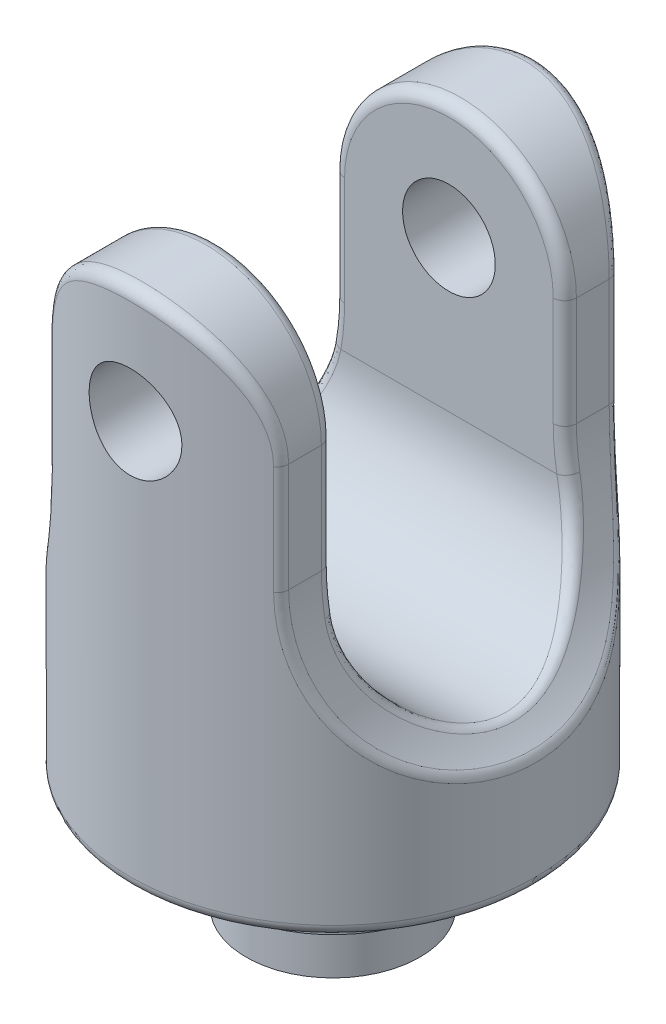
from build123d import *

# Parameters (mm, degrees)
SKETCH_1_R               = 17.5
EXTRUDE_1_DEPTH          = 45
CUT_EXTRUDE_1_DEPTH      = 18.5
CUT_EXTRUDE_1_DEPTH_BACK = 18.5
CUT_EXTRUDE_3_DEPTH      = 18.5000001
CUT_EXTRUDE_3_DEPTH_BACK = 18.5000001
SKETCH_4_R               = 4
CUT_EXTRUDE_4_DEPTH      = 18.5000001
CUT_EXTRUDE_4_DEPTH_BACK = 18.5000001
SKETCH_5_R               = 10
EXTRUDE_2_DEPTH          = 5
SKETCH_6_R               = 7.5
EXTRUDE_3_DEPTH          = 5
FILLET_1_R               = 1


with BuildPart() as part:
    # 草图1 → 凸台-拉伸1 (new body)
    with BuildSketch(Plane(origin=(0, 0, 0), x_dir=(1, 0, 0), z_dir=(0, 1, 0))):
        Circle(SKETCH_1_R)
    extrude(amount=EXTRUDE_1_DEPTH)

    # 草图2 → 切除-拉伸1 (cut, two sides)
    with BuildSketch(Plane.XY) as cut_extrude_1_sk:
        with BuildLine():
            Line((102.584155078, -58.121843354), (17.5, 10))
            ThreePointArc((17.5, 10), (11.972243623, 16.952240958), (10, 25.612494996))
            Line((10, 25.612494996), (10, 35))
            ThreePointArc((10, 35), (0, 45), (-10, 35))
            Line((-10, 35), (-10, 25.612494996))
            ThreePointArc((-10, 25.612494996), (-11.972243623, 16.952240958), (-17.5, 10))
            Line((-17.5, 10), (-102.584155078, -58.121843354))
            Line((-102.584155078, -58.121843354), (-102.584155078, 159.868055378))
            Line((-102.584155078, 159.868055378), (102.584155078, 159.868055378))
            Line((102.584155078, 159.868055378), (102.584155078, -58.121843354))
        make_face()
    extrude(amount=CUT_EXTRUDE_1_DEPTH, mode=Mode.SUBTRACT)
    extrude(cut_extrude_1_sk.sketch, amount=-CUT_EXTRUDE_1_DEPTH_BACK, mode=Mode.SUBTRACT)

    # 草图3 → 切除-拉伸3 (cut, two sides)
    with BuildSketch(Plane(origin=(0, 0, 0), x_dir=(0, 0, -1), z_dir=(1, 0, 0))) as cut_extrude_3_sk:
        with BuildLine():
            Line((-10, 45), (-10, 22))
            ThreePointArc((-10, 22), (0, 12), (10, 22))
            Line((10, 22), (10, 45))
            Line((10, 45), (-10, 45))
        make_face()
    extrude(amount=CUT_EXTRUDE_3_DEPTH, mode=Mode.SUBTRACT)
    extrude(cut_extrude_3_sk.sketch, amount=-CUT_EXTRUDE_3_DEPTH_BACK, mode=Mode.SUBTRACT)

    # 草图4 → 切除-拉伸4 (cut, two sides)
    with BuildSketch(Plane.XY) as cut_extrude_4_sk:
        with Locations((0, 35)):
            Circle(SKETCH_4_R)
    extrude(amount=CUT_EXTRUDE_4_DEPTH, mode=Mode.SUBTRACT)
    extrude(cut_extrude_4_sk.sketch, amount=-CUT_EXTRUDE_4_DEPTH_BACK, mode=Mode.SUBTRACT)

    # 草图5 → 凸台-拉伸2 (add)
    with BuildSketch(Plane.XZ):
        Circle(SKETCH_5_R)
    extrude(amount=EXTRUDE_2_DEPTH)

    # 草图6 → 凸台-拉伸3 (add)
    with BuildSketch(Plane.XZ.offset(5)):
        Circle(SKETCH_6_R)
    extrude(amount=EXTRUDE_3_DEPTH)

    # 圆角1
    fillet_1_edges = [part.edges().sort_by_distance(p)[0] for p in [
        (-10, 30.306247498, -14.361406616),
        (-13.616418012, 14.141739086, -10.99286862),
        (0, 45, -17.5),
        (0, 45, 17.5),
        (-17.5, 0, 0),
        (0, 45, 10),
        (0, 45, -10),
        (15.347355871, 12, 0),
        (-15.347355871, 12, 0),
        (10.082409368, 23.798774118, -10),
        (10, 30.306247498, -10),
        (-10, 30.306247498, -10),
        (-10.082409368, 23.798774118, -10),
        (10, 30.306247498, 10),
        (10.082409368, 23.798774118, 10),
        (-10.082409368, 23.798774118, 10),
        (-10, 30.306247498, 10),
        (13.616418165, 14.141738868, 10.992868431),
        (10, 30.306247498, -14.361406616),
        (10, 30.306247498, 14.361406616),
        (-10, 30.306247498, 14.361406616),
    ]]
    fillet(fillet_1_edges, radius=FILLET_1_R)


solid = part.part
